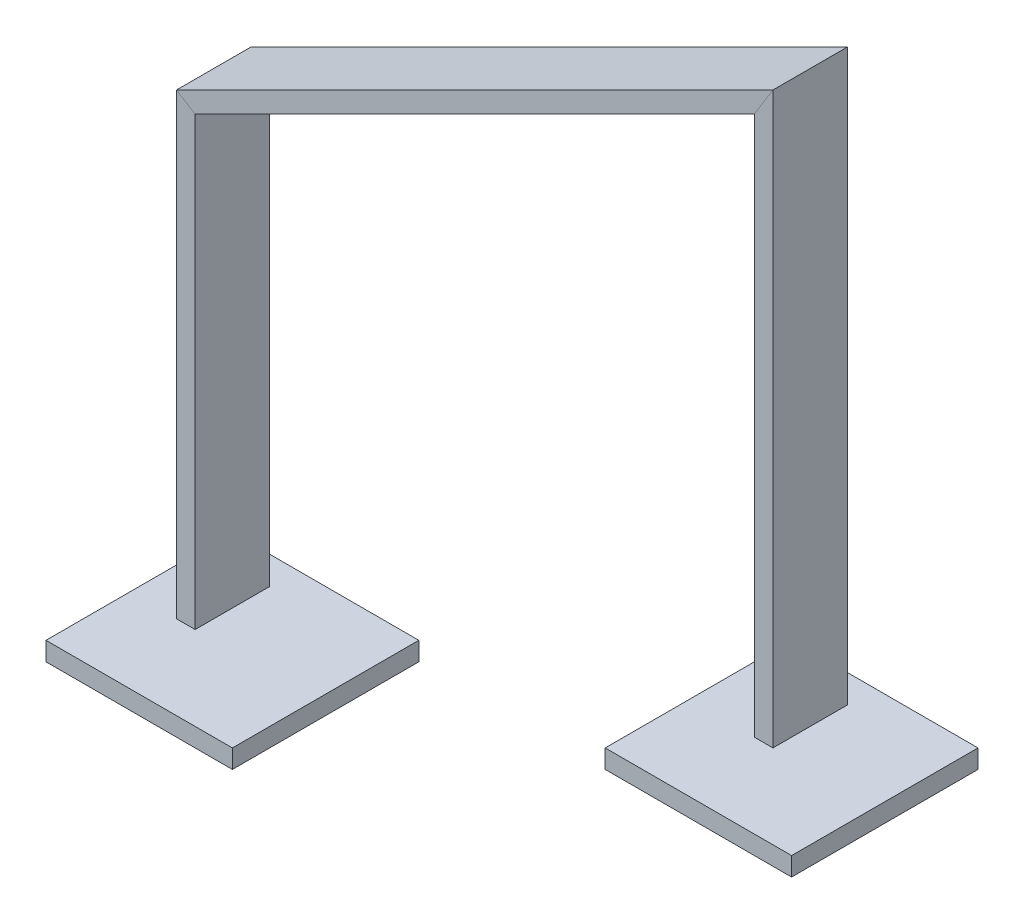
from build123d import *

# Parameters (mm, degrees)
SKIZZE1_W                       = 100
SKIZZE1_H                       = 100
AUFSATZ_LINEAR_AUSTRAGEN1_DEPTH = 10
SKIZZE2_W                       = 100
SKIZZE2_H                       = 10
AUFSATZ_LINEAR_AUSTRAGEN2_DEPTH = 50
SKIZZE4_W                       = 10
SKIZZE4_H                       = 40
FL_CHE_VERSCHIEBEN1_BY          = 15
FL_CHE_VERSCHIEBEN1_2_BY        = 15


with BuildPart() as part:
    # Skizze1 → Aufsatz-Linear austragen1 (new body)
    with BuildSketch(Plane(origin=(0, 0, 0), x_dir=(1, 0, 0), z_dir=(0, 1, 0))):
        with Locations((50, 0)):
            Rectangle(SKIZZE1_W, SKIZZE1_H)
    extrude(amount=AUFSATZ_LINEAR_AUSTRAGEN1_DEPTH)


with BuildPart() as body_2:
    # Skizze2 → Aufsatz-Linear austragen2 (new, symmetric)
    with BuildSketch(Plane.XY):
        with Locations((350, 105)):
            Rectangle(SKIZZE2_W, SKIZZE2_H)
    extrude(amount=AUFSATZ_LINEAR_AUSTRAGEN2_DEPTH, both=True)


with BuildPart() as body_3:
    # Austragung1: sweep along a path in Skizze3
    with BuildLine(Plane.XY) as austragung1_path:
        Line((50, 10), (50, 264.508497187))
        Line((50, 264.508497187), (350, 414.508497187))
        Line((350, 414.508497187), (350, 110))
    # Skizze4 → Austragung1 (sweep)
    with BuildSketch(Plane(origin=(0, 10, 0), x_dir=(1, 0, 0), z_dir=(0, 1, 0))):
        with Locations((45, 0)):
            Rectangle(SKIZZE4_W, SKIZZE4_H)
    sweep(path=austragung1_path.line, transition=Transition.RIGHT)

    # Fläche verschieben1: a face moved inward by 15.0
    extrude(body_3.faces().sort_by_distance((355, 110, 0))[0], amount=FL_CHE_VERSCHIEBEN1_BY, dir=(0, 1, 0), mode=Mode.SUBTRACT)

    # Fl_che verschieben1 2: a face moved inward by 15.0
    extrude(body_3.faces().sort_by_distance((45, 10, 0))[0], amount=FL_CHE_VERSCHIEBEN1_2_BY, dir=(0, 1, 0), mode=Mode.SUBTRACT)


solid = Compound([part.part, body_2.part, body_3.part])
